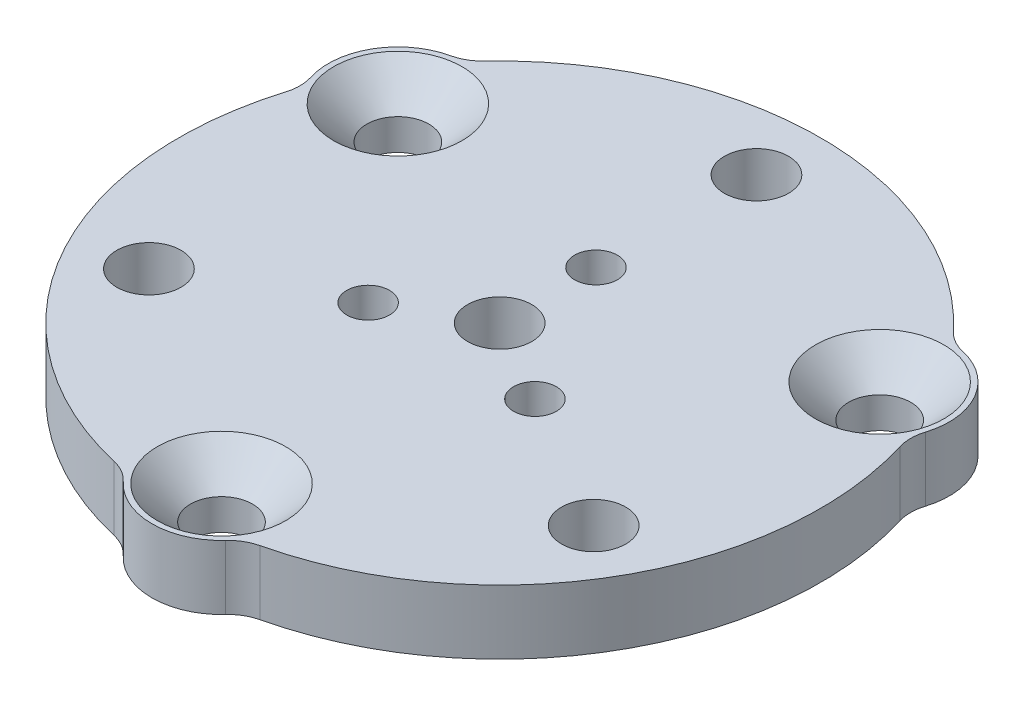
from build123d import *

# Parameters (mm, degrees)
SKETCH_1_R      = 15
SKETCH_1_R_2    = 1.45
SKETCH_1_R_3    = 1.5
SKETCH_1_R_4    = 1
EXTRUDE_1_DEPTH = 3
CHAMFER_1_SIZE  = 1
SKETCH_2_R      = 3.25
SKETCH_2_R_2    = 1.45
EXTRUDE_2_DEPTH = 3
CHAMFER_2_SIZE  = 1.55
FILLET_1_R      = 2


with BuildPart() as part:
    # 草图1 → 凸台-拉伸1 (new body)
    with BuildSketch(Plane(origin=(0, 0, 0), x_dir=(1, 0, 0), z_dir=(0, 1, 0))):
        Circle(SKETCH_1_R)
        with Locations((0, -13)):
            Circle(SKETCH_1_R_2, mode=Mode.SUBTRACT)
        with Locations((-11.258330249, 6.5)):
            Circle(SKETCH_1_R_2, mode=Mode.SUBTRACT)
        with Locations((11.258330249, 6.5)):
            Circle(SKETCH_1_R_2, mode=Mode.SUBTRACT)
        with Locations((0, 12)):
            Circle(SKETCH_1_R_3, mode=Mode.SUBTRACT)
        with Locations((10.392304845, -6)):
            Circle(SKETCH_1_R_3, mode=Mode.SUBTRACT)
        with Locations((-10.392304845, -6)):
            Circle(SKETCH_1_R_3, mode=Mode.SUBTRACT)
        with Locations((0, 4.5)):
            Circle(SKETCH_1_R_4, mode=Mode.SUBTRACT)
        with Locations((3.897114317, -2.25)):
            Circle(SKETCH_1_R_4, mode=Mode.SUBTRACT)
        with Locations((-3.897114317, -2.25)):
            Circle(SKETCH_1_R_4, mode=Mode.SUBTRACT)
        Circle(SKETCH_1_R_3, mode=Mode.SUBTRACT)
    extrude(amount=EXTRUDE_1_DEPTH)

    # 倒角1
    chamfer_1_edges = [part.edges().sort_by_distance(p)[0] for p in [
        (-1, 0, -4.5),
        (2.897114317, 0, 2.25),
        (-4.897114317, 0, 2.25),
    ]]
    chamfer(chamfer_1_edges, length=CHAMFER_1_SIZE)

    # 草图2 → 凸台-拉伸2 (add)
    with BuildSketch(Plane(origin=(0, 3, 0), x_dir=(1, 0, 0), z_dir=(0, 1, 0))):
        with Locations((11.258330249, 6.5)):
            Circle(SKETCH_2_R)
        with Locations((11.258330249, 6.5)):
            Circle(SKETCH_2_R_2, mode=Mode.SUBTRACT)
        with Locations((0, -13)):
            Circle(SKETCH_2_R)
        with Locations((0, -13)):
            Circle(SKETCH_2_R_2, mode=Mode.SUBTRACT)
        with Locations((-11.258330249, 6.5)):
            Circle(SKETCH_2_R)
        with Locations((-11.258330249, 6.5)):
            Circle(SKETCH_2_R_2, mode=Mode.SUBTRACT)
    extrude(amount=-EXTRUDE_2_DEPTH)

    # 倒角2
    chamfer_2_edges = [part.edges().sort_by_distance(p)[0] for p in [
        (9.808330249, 3, -6.5),
        (-1.45, 3, 13),
        (-12.708330249, 3, -6.5),
    ]]
    chamfer(chamfer_2_edges, length=CHAMFER_2_SIZE)

    # 圆角1
    fillet_1_edges = [part.edges().sort_by_distance(p)[0] for p in [
        (11.401719222, 1.5, -9.746835321),
        (14.141866606, 1.5, -5.000760833),
        (2.740147383, 1.5, 14.747596154),
        (-2.740147383, 1.5, 14.747596154),
        (-11.401719222, 1.5, -9.746835321),
        (-14.141866606, 1.5, -5.000760833),
    ]]
    fillet(fillet_1_edges, radius=FILLET_1_R)


solid = part.part
